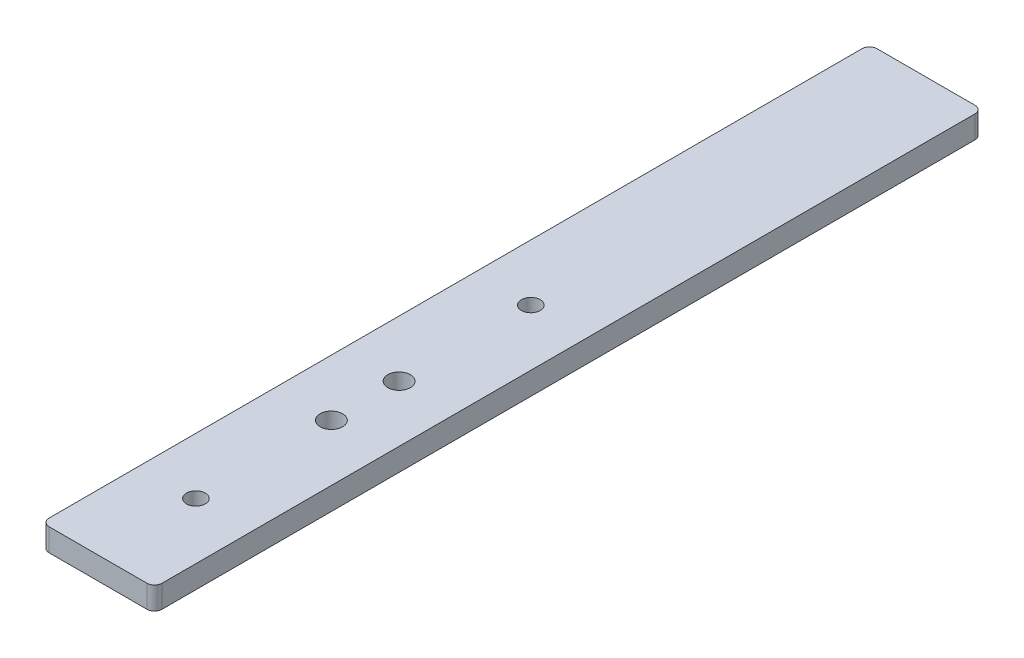
from build123d import *

# Parameters (mm, degrees)
SKETCH_1_W          = 15
SKETCH_1_H          = 110
EXTRUDE_1_DEPTH     = 3
FILLET_1_R          = 1
SKETCH_2_R          = 1.25
CUT_EXTRUDE_1_DEPTH = 3
SKETCH_3_R          = 1.5
CUT_EXTRUDE_2_DEPTH = 10


with BuildPart() as part:
    # 草图1 → 凸台-拉伸1 (new body)
    with BuildSketch(Plane(origin=(0, 0, 0), x_dir=(1, 0, 0), z_dir=(0, 1, 0))):
        with Locations((7.5, 55)):
            Rectangle(SKETCH_1_W, SKETCH_1_H)
    extrude(amount=EXTRUDE_1_DEPTH)

    # 圆角1
    fillet_1_edges = [part.edges().sort_by_distance(p)[0] for p in [
        (0, 1.5, -110),
        (15, 1.5, -110),
        (15, 1.5, 0),
        (0, 1.5, 0),
    ]]
    fillet(fillet_1_edges, radius=FILLET_1_R)

    # 草图2 → 切除-拉伸1 (cut)
    with BuildSketch(Plane(origin=(0, 3, 0), x_dir=(1, 0, 0), z_dir=(0, 1, 0))):
        with Locations((7.5, 13)):
            Circle(SKETCH_2_R)
        with Locations((7.5, 57.5)):
            Circle(SKETCH_2_R)
    extrude(amount=-CUT_EXTRUDE_1_DEPTH, mode=Mode.SUBTRACT)

    # 草图3 → 切除-拉伸2 (cut)
    with BuildSketch(Plane(origin=(0, 3, 0), x_dir=(1, 0, 0), z_dir=(0, 1, 0))):
        with Locations((7.5, 40)):
            Circle(SKETCH_3_R)
        with Locations((7.5, 31)):
            Circle(SKETCH_3_R)
    extrude(amount=-CUT_EXTRUDE_2_DEPTH, mode=Mode.SUBTRACT)


solid = part.part
